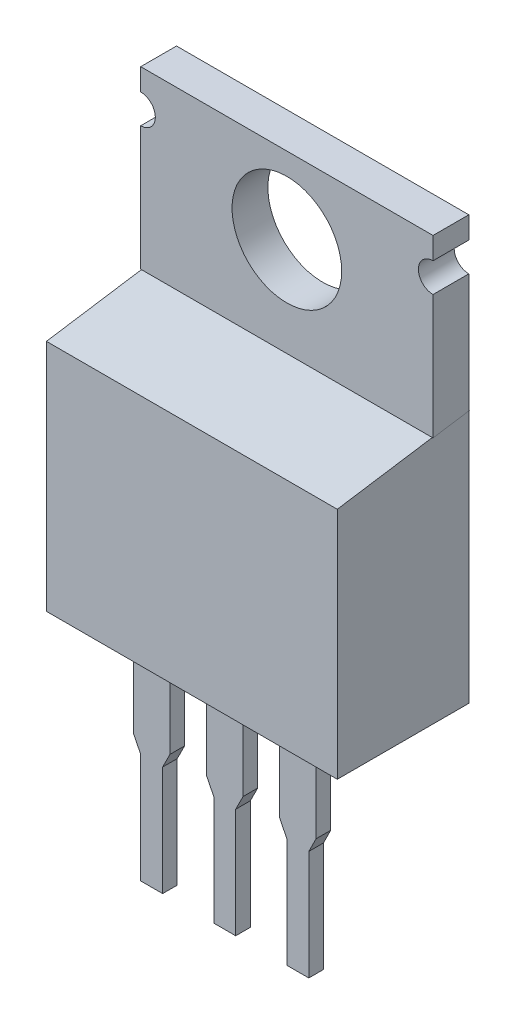
from build123d import *

# Parameters (mm, degrees)
SKETCH2_W                = 10.16
SKETCH2_H                = 4.572
BASE_EXTRUDE_DEPTH       = 14.732
CUT_EXTRUDE1_DEPTH       = 1
CUT_EXTRUDE1_DEPTH_BACK  = 11.16
SKETCH4_R                = 1.905
CUT_EXTRUDE2_DEPTH       = 14.732
CUT_EXTRUDE4_DEPTH       = 0.0254
CUT_EXTRUDE5_DEPTH       = 0.0254
CUT_EXTRUDE6_DEPTH       = 0.0254
CUT_EXTRUDE7_DEPTH       = 2.54
SKETCH9_W                = 1.27
SKETCH9_H                = 7.62
BOSS_EXTRUDE_THIN1_DEPTH = 0.254
CUT_EXTRUDE8_DEPTH       = 1.27
LPATTERN1_COUNT          = 3
LPATTERN1_PITCH          = 2.54


with BuildPart() as part:
    # Sketch2 → Base-Extrude (new body)
    with BuildSketch(Plane(origin=(0, 3.81, 0), x_dir=(-1, 0, 0), z_dir=(0, 1, 0))):
        with Locations((-2.54, -0.889)):
            Rectangle(SKETCH2_W, SKETCH2_H)
    extrude(amount=BASE_EXTRUDE_DEPTH)

    # Sketch3 → Cut-Extrude1 (cut, two sides)
    with BuildSketch(Plane.ZY.offset(2.54)) as cut_extrude1_sk:
        Polygon((-1.905, 18.542), (-1.905, 12.446), (1.397, 11.938), (1.397, 18.542), align=None)
    extrude(amount=CUT_EXTRUDE1_DEPTH, mode=Mode.SUBTRACT)
    extrude(cut_extrude1_sk.sketch, amount=-CUT_EXTRUDE1_DEPTH_BACK, mode=Mode.SUBTRACT)

    # Sketch4 → Cut-Extrude2 (cut)
    with BuildSketch(Plane.XY.offset(-1.905)):
        with Locations((2.54, 15.875)):
            Circle(SKETCH4_R)
    extrude(amount=-CUT_EXTRUDE2_DEPTH, mode=Mode.SUBTRACT)

    # Sketch5 → Cut-Extrude4 (cut)
    with BuildSketch(Plane.ZY.offset(2.54)):
        Polygon((-3.175, 12.641384615), (1.397, 11.938), (1.397, 3.81), (-3.175, 3.81), align=None)
    extrude(amount=-CUT_EXTRUDE4_DEPTH, mode=Mode.SUBTRACT)

    # Sketch6 → Cut-Extrude5 (cut)
    with BuildSketch(Plane(origin=(7.62, 0, 0), x_dir=(0, 0, -1), z_dir=(1, 0, 0))):
        Polygon((-1.397, 11.938), (3.175, 12.641384615), (3.175, 3.81), (-1.397, 3.81), align=None)
    extrude(amount=-CUT_EXTRUDE5_DEPTH, mode=Mode.SUBTRACT)

    # Sketch7 → Cut-Extrude6 (cut)
    with BuildSketch(Plane(origin=(0, 0, -3.175), x_dir=(-1, 0, 0), z_dir=(0, 0, -1))):
        Polygon((-7.62, 18.542), (-7.62, 12.641384615), (-6.35, 12.641384615), (-6.35, 7.112), (1.27, 7.112), (1.27, 12.641384615), (2.54, 12.641384615), (2.54, 18.542), align=None)
    extrude(amount=-CUT_EXTRUDE6_DEPTH, mode=Mode.SUBTRACT)

    # Sketch8 → Cut-Extrude7 (cut)
    with BuildSketch(Plane.XY.offset(-1.905)):
        with BuildLine():
            Line((7.62, 16.764), (7.62, 17.78))
            ThreePointArc((7.62, 17.78), (7.112, 17.272), (7.62, 16.764))
        make_face()
        with BuildLine():
            Line((-2.54, 16.764), (-2.54, 17.78))
            ThreePointArc((-2.54, 17.78), (-2.032, 17.272), (-2.54, 16.764))
        make_face()
    extrude(amount=-CUT_EXTRUDE7_DEPTH, mode=Mode.SUBTRACT)

    # Sketch9 → Boss-Extrude-Thin1 (add, symmetric)
    with BuildSketch(Plane.XY):
        Rectangle(SKETCH9_W, SKETCH9_H)
    boss_extrude_thin1 = extrude(amount=BOSS_EXTRUDE_THIN1_DEPTH, both=True)

    # Sketch11 → Cut-Extrude8 (cut)
    with BuildSketch(Plane.XY.offset(0.254)):
        Polygon((0.635, 0.508), (0.635, -3.81), (0.381, -3.81), (0.381, 0), align=None)
        Polygon((-0.635, 0.508), (-0.635, -3.81), (-0.381, -3.81), (-0.381, 0), align=None)
    cut_extrude8 = extrude(amount=-CUT_EXTRUDE8_DEPTH, mode=Mode.SUBTRACT)

    # LPattern1: Boss-Extrude-Thin1, Cut-Extrude8 ×3
    with Locations(*[(i * LPATTERN1_PITCH, 0, 0) for i in range(1, LPATTERN1_COUNT)]):
        add(boss_extrude_thin1)
        add(cut_extrude8, mode=Mode.SUBTRACT)


solid = part.part
